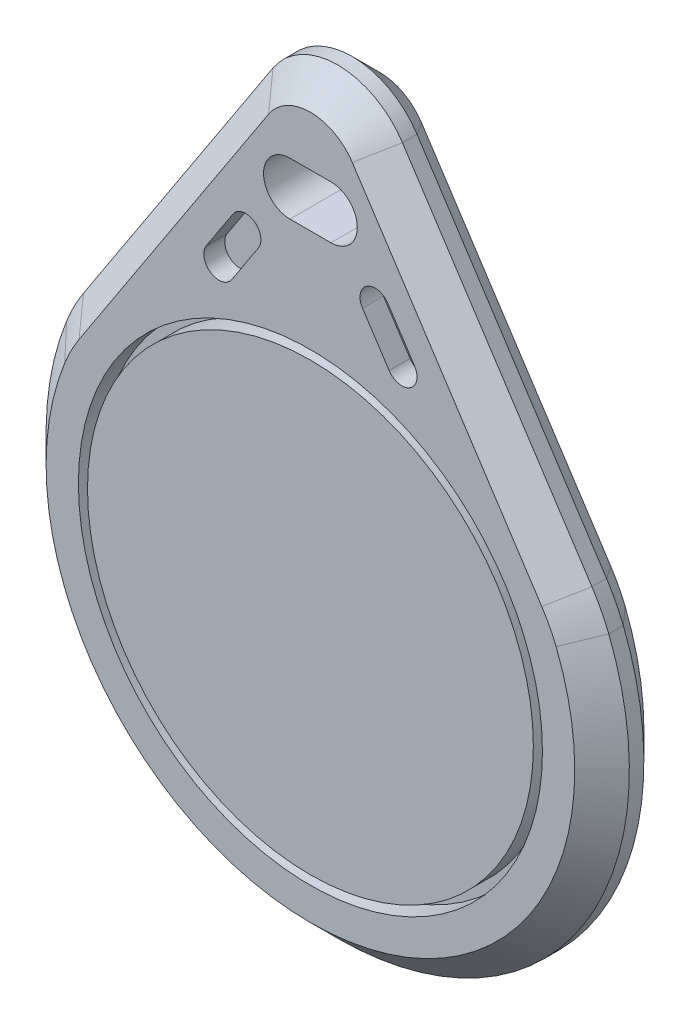
from build123d import *

# Parameters (mm, degrees)
ESBO_O1_R                  = 12.75
RESSALTO_EXTRUS_O1_DEPTH   = 1.9
ESBO_O1_R_2                = 12.25
RESSALTO_EXTRUS_O1_2_DEPTH = 1.9
ESBO_O1_3_R                = 12.75
ESBO_O1_3_R_2              = 12.25
RESSALTO_EXTRUS_O2_DEPTH   = 0.75
CHANFRO1_SIZE              = 1.5
ESBO_O1_4_R                = 12.75
ESBO_O1_4_R_2              = 12.25
RESSALTO_EXTRUS_O3_DEPTH   = 1.9


with BuildPart() as part:
    # Esboço1 → Ressalto-extrusão1 (new, symmetric)
    with BuildSketch(Plane.XY):
        with BuildLine():
            Line((-3.557120859, 23.620523756), (-13.969531124, 7.695660998))
            ThreePointArc((-13.969531124, 7.695660998), (-14.476708195, 6.827634982), (-14.894166908, 5.913071715))
            ThreePointArc((-14.894166908, 5.913071715), (0, -16.025), (14.894166908, 5.913071715))
            ThreePointArc((14.894166908, 5.913071715), (14.476708195, 6.827634982), (13.969531124, 7.695660998))
            Line((13.969531124, 7.695660998), (3.557120859, 23.620523756))
            ThreePointArc((3.557120859, 23.620523756), (0, 25.544713963), (-3.557120859, 23.620523756))
        make_face()
        Circle(ESBO_O1_R, mode=Mode.SUBTRACT)
        with BuildLine():
            ThreePointArc((-4.255990487, 17.069702714), (-3.100167641, 17.311619123), (-2.858251232, 16.155796277))
            Line((-2.858251232, 16.155796277), (-4.324879525, 13.912717712))
            ThreePointArc((-4.324879525, 13.912717712), (-5.48070237, 13.670801302), (-5.72261878, 14.826624148))
            Line((-5.72261878, 14.826624148), (-4.255990487, 17.069702714))
        make_face(mode=Mode.SUBTRACT)
        with BuildLine():
            ThreePointArc((1.125, 21.294713963), (2.575, 19.844713963), (1.125, 18.394713963))
            Line((1.125, 18.394713963), (-1.125, 18.394713963))
            ThreePointArc((-1.125, 18.394713963), (-2.575, 19.844713963), (-1.125, 21.294713963))
            Line((-1.125, 21.294713963), (1.125, 21.294713963))
        make_face(mode=Mode.SUBTRACT)
        with BuildLine():
            Line((4.324879525, 13.912717712), (2.858251232, 16.155796277))
            ThreePointArc((2.858251232, 16.155796277), (3.100167641, 17.311619123), (4.255990487, 17.069702714))
            Line((4.255990487, 17.069702714), (5.72261878, 14.826624148))
            ThreePointArc((5.72261878, 14.826624148), (5.48070237, 13.670801302), (4.324879525, 13.912717712))
        make_face(mode=Mode.SUBTRACT)
    extrude(amount=RESSALTO_EXTRUS_O1_DEPTH, both=True)



with BuildPart() as body_2:
    # Esboço1 → Ressalto-extrus_o1 2 (new, symmetric)
    with BuildSketch(Plane.XY):
        Circle(ESBO_O1_R_2)
    extrude(amount=RESSALTO_EXTRUS_O1_2_DEPTH, both=True)


with BuildPart() as part_1:
    add(part.part)

    add(body_2.part)  # Ressalto-extrusão2 merges body 2
    # Esboço1<3> → Ressalto-extrusão2 (add, symmetric)
    # profile 1 of 3: a face of its own
    with BuildSketch(Plane.XY):
        with BuildLine():
            Line((-4.324879525, 13.912717712), (-2.858251232, 16.155796277))
            ThreePointArc((-2.858251232, 16.155796277), (-3.100167641, 17.311619123), (-4.255990487, 17.069702714))
            Line((-4.255990487, 17.069702714), (-5.72261878, 14.826624148))
            ThreePointArc((-5.72261878, 14.826624148), (-5.48070237, 13.670801302), (-4.324879525, 13.912717712))
        make_face()
    # profile 2 of 3: a face of its own
    with BuildSketch(Plane.XY):
        with BuildLine():
            ThreePointArc((4.255990487, 17.069702714), (3.100167641, 17.311619123), (2.858251232, 16.155796277))
            Line((2.858251232, 16.155796277), (4.324879525, 13.912717712))
            ThreePointArc((4.324879525, 13.912717712), (5.48070237, 13.670801302), (5.72261878, 14.826624148))
            Line((5.72261878, 14.826624148), (4.255990487, 17.069702714))
        make_face()
    # profile 3 of 3: a face of its own
    with BuildSketch(Plane.XY):
        Circle(ESBO_O1_3_R)
        Circle(ESBO_O1_3_R_2, mode=Mode.SUBTRACT)
    extrude(amount=RESSALTO_EXTRUS_O2_DEPTH, both=True)

    # Chanfro1
    chanfro1_edges = [part_1.edges().sort_by_distance(p)[0] for p in [
        (-14.476708195, 6.827634982, -1.9),
        (0, -16.025, -1.9),
        (-8.763325992, 15.658092377, -1.9),
        (14.476708195, 6.827634982, -1.9),
        (0, 25.544713963, -1.9),
        (8.763325992, 15.658092377, -1.9),
        (0, -16.025, 1.9),
        (14.476708195, 6.827634982, 1.9),
        (-14.476708195, 6.827634982, 1.9),
        (8.763325992, 15.658092377, 1.9),
        (-8.763325992, 15.658092377, 1.9),
        (0, 25.544713963, 1.9),
    ]]
    chamfer(chanfro1_edges, length=CHANFRO1_SIZE)

    # Esboço1<4> → Ressalto-extrusão3 (add)
    with BuildSketch(Plane.XY):
        Circle(ESBO_O1_4_R)
        Circle(ESBO_O1_4_R_2, mode=Mode.SUBTRACT)
    extrude(amount=-RESSALTO_EXTRUS_O3_DEPTH)


solid = part_1.part
